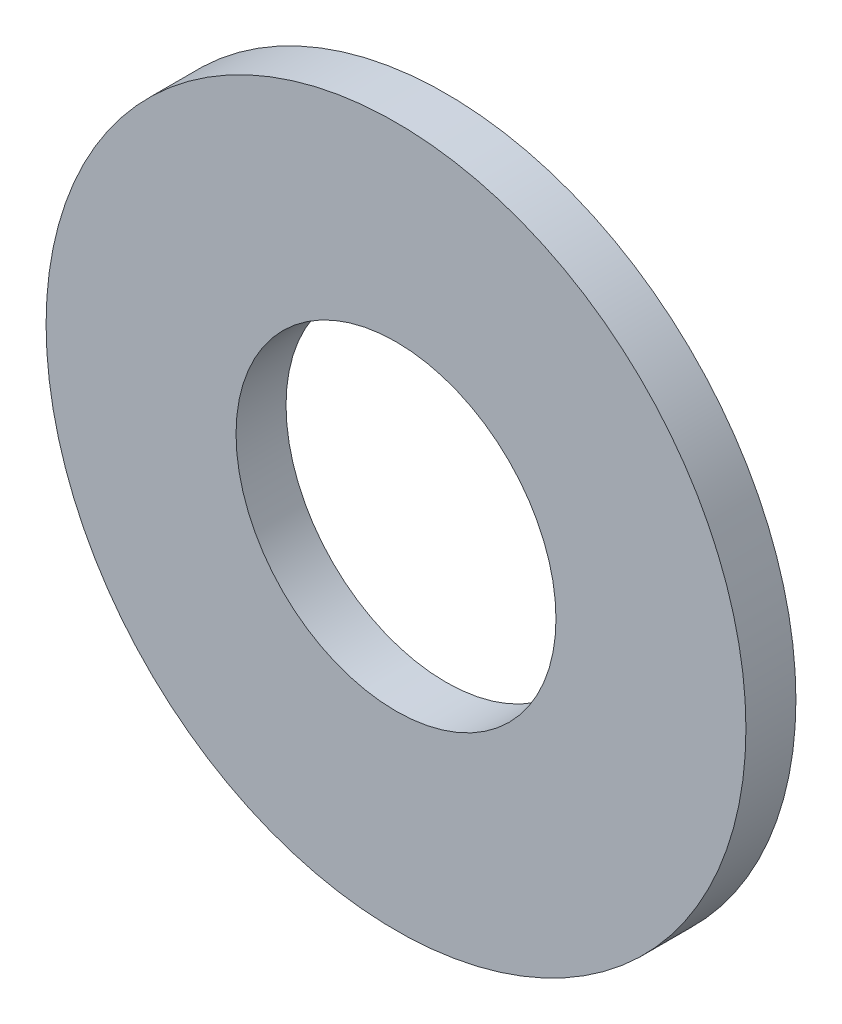
from build123d import *

# Parameters (mm, degrees)
SKETCH_1_R      = 3.5
SKETCH_1_R_2    = 1.6
EXTRUDE_1_DEPTH = 0.5


with BuildPart() as part:
    # Эскиз1 → Бобышка-Вытянуть1 (new body)
    with BuildSketch(Plane.XY):
        Circle(SKETCH_1_R)
        Circle(SKETCH_1_R_2, mode=Mode.SUBTRACT)
    extrude(amount=EXTRUDE_1_DEPTH)


solid = part.part
